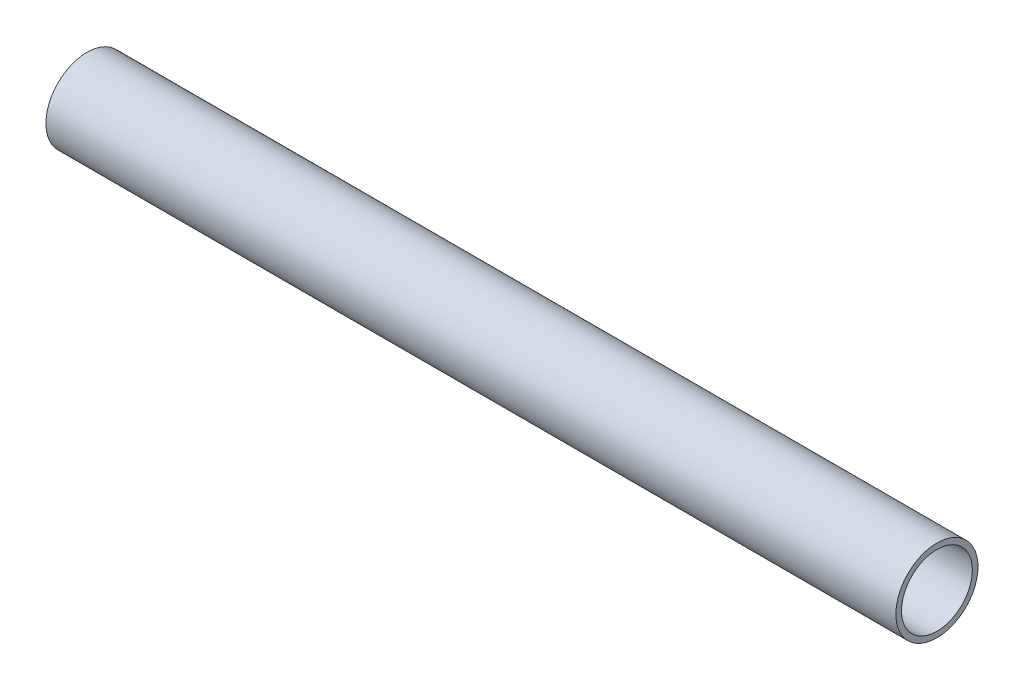
from build123d import *

# Parameters (mm, degrees)
SWEEP_THIN1_PROFILE_R   = 14.5
SWEEP_THIN1_PROFILE_R_2 = 12.5


with BuildPart() as part:
    # Sweep-Thin1: sweep along a path in Sketch1
    with BuildLine(Plane.XY) as sweep_thin1_path:
        Line((0, 0), (300, 0))
    # Sweep-Thin1 profile (on start of the path) → Sweep-Thin1 (sweep)
    with BuildSketch(Plane(origin=(0, 0, 0), x_dir=(0, 0, 1), z_dir=(1, 0, 0))):
        Circle(SWEEP_THIN1_PROFILE_R)
        Circle(SWEEP_THIN1_PROFILE_R_2, mode=Mode.SUBTRACT)
    sweep(path=sweep_thin1_path.line)


solid = part.part
